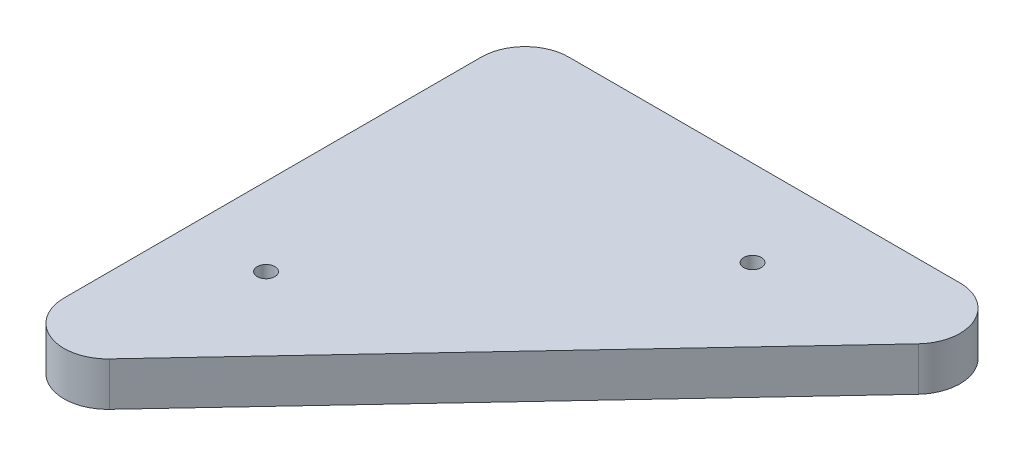
from build123d import *

# Parameters (mm, degrees)
BOSS_EXTRUDE1_DEPTH         = 12.7
F_1_4_20_TAPPED_HOLE1_D     = 5.1054
F_1_4_20_TAPPED_HOLE1_DEPTH = 19.05
F_1_4_20_TAPPED_HOLE1_TIP   = 1.533816902


with BuildPart() as part:
    # Sketch1 → Boss-Extrude1 (new body)
    with BuildSketch(Plane(origin=(0, 0, 0), x_dir=(1, 0, 0), z_dir=(0, 1, 0))):
        with BuildLine():
            Line((-12.7, 121.25), (-12.7, 0))
            ThreePointArc((-12.7, 0), (-4.670226784, -11.810122005), (9.265193981, -8.685976081))
            Line((9.265193981, -8.685976081), (122.935193981, 112.564023919))
            ThreePointArc((122.935193981, 112.564023919), (125.323366386, 126.298668328), (113.67, 133.95))
            Line((113.67, 133.95), (0, 133.95))
            ThreePointArc((0, 133.95), (-8.980256121, 130.230256121), (-12.7, 121.25))
        make_face()
    extrude(amount=BOSS_EXTRUDE1_DEPTH)

    # 1/4-20 Tapped Hole1
    with Locations(Plane(origin=(10.018427162, 12.7, -35.98129538), x_dir=(0, 0, 1), z_dir=(0, 1, 0))):
        with Locations((0, 0), (-72.954283318, 68.393512452)):
            Hole(F_1_4_20_TAPPED_HOLE1_D / 2, depth=F_1_4_20_TAPPED_HOLE1_DEPTH)
            with Locations((0, 0, -(F_1_4_20_TAPPED_HOLE1_DEPTH + F_1_4_20_TAPPED_HOLE1_TIP / 2))):  # 118° drill point
                Cone(0, F_1_4_20_TAPPED_HOLE1_D / 2, F_1_4_20_TAPPED_HOLE1_TIP, mode=Mode.SUBTRACT)


solid = part.part
